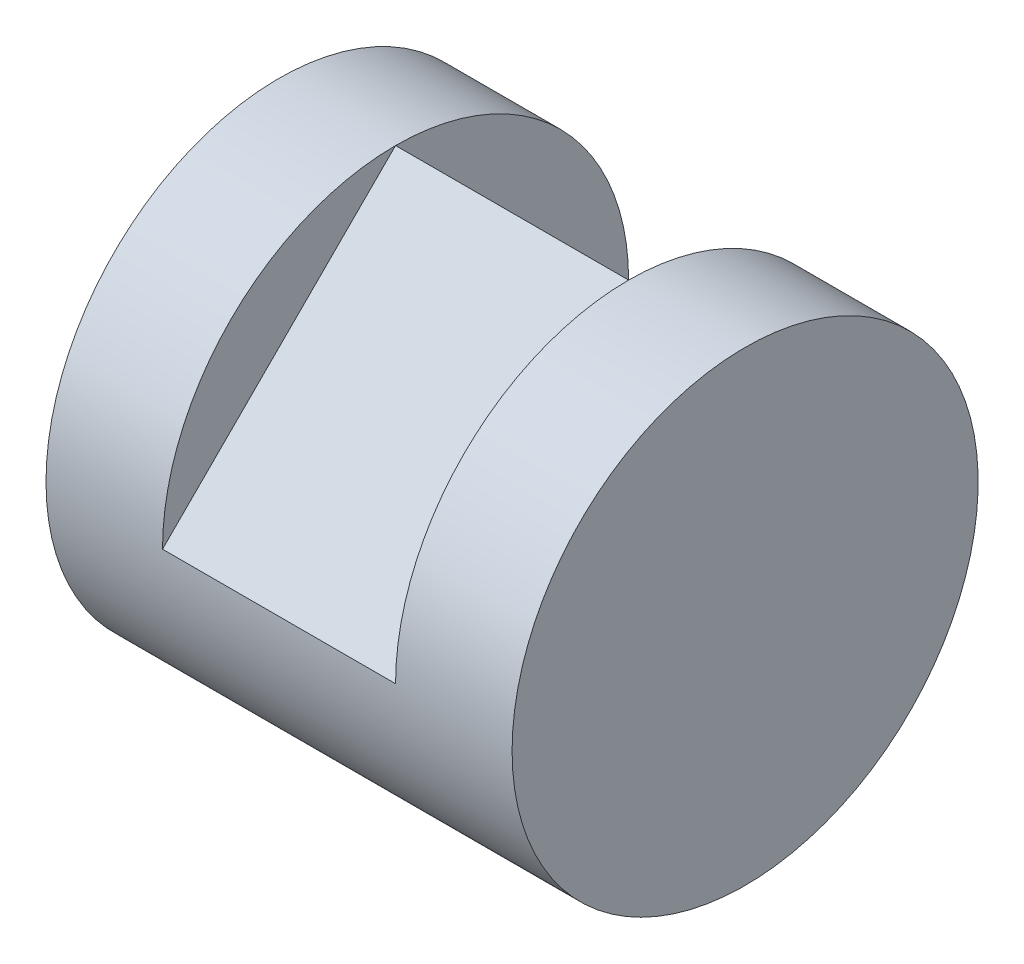
from build123d import *

# Parameters (mm, degrees)
SKETCH1_W           = 40
SKETCH1_H           = 40
BOSS_EXTRUDE1_DEPTH = 40
CUT_EXTRUDE1_DEPTH  = 71
SKETCH3_W           = 20
SKETCH3_H           = 20
CUT_EXTRUDE2_DEPTH  = 71
BOSS_EXTRUDE2_DEPTH = 20


with BuildPart() as part:
    # Sketch1 → Boss-Extrude1 (new body)
    with BuildSketch(Plane.XY):
        with Locations((20, 20)):
            Rectangle(SKETCH1_W, SKETCH1_H)
    extrude(amount=BOSS_EXTRUDE1_DEPTH)

    # Sketch2 → Cut-Extrude1 (cut)
    with BuildSketch(Plane.ZY):
        with BuildLine():
            Line((20, 40), (0, 40))
            Line((0, 40), (0, 20))
            ThreePointArc((0, 20), (5.857864376, 34.142135624), (20, 40))
        make_face()
        with BuildLine():
            Line((40, 40), (20, 40))
            ThreePointArc((20, 40), (34.142135624, 34.142135624), (40, 20))
            Line((40, 20), (40, 40))
        make_face()
        with BuildLine():
            Line((40, 0), (40, 20))
            ThreePointArc((40, 20), (34.142135624, 5.857864376), (20, 0))
            Line((20, 0), (40, 0))
        make_face()
        with BuildLine():
            ThreePointArc((20, 0), (5.857864376, 5.857864376), (0, 20))
            Line((0, 20), (0, 0))
            Line((0, 0), (20, 0))
        make_face()
    extrude(amount=-CUT_EXTRUDE1_DEPTH, mode=Mode.SUBTRACT)

    # Sketch3 → Cut-Extrude2 (cut)
    with BuildSketch(Plane.XY):
        with Locations((20, 30)):
            Rectangle(SKETCH3_W, SKETCH3_H)
    extrude(amount=CUT_EXTRUDE2_DEPTH, mode=Mode.SUBTRACT)

    # Sketch4 → Boss-Extrude2 (add)
    with BuildSketch(Plane(origin=(10, 0, 0), x_dir=(0, 0, -1), z_dir=(1, 0, 0))):
        Polygon((-40, 20), (-20, 20), (-20, 40), align=None)
        Polygon((-20, 40), (-20, 20), (0, 20), align=None)
    extrude(amount=BOSS_EXTRUDE2_DEPTH)


solid = part.part
